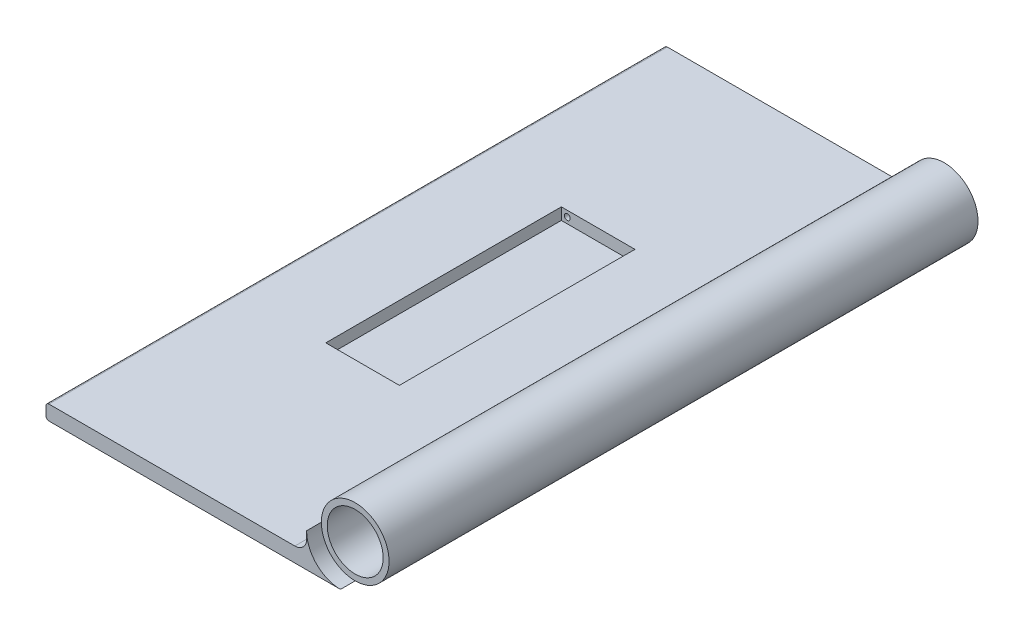
from build123d import *

# Parameters (mm, degrees)
SKETCH_1_R               = 11.5
SKETCH_1_R_2             = 9.5
EXTRUDE_1_DEPTH          = 200
EXTRUDE_2_DEPTH          = 5
EXTRUDE_2_DEPTH_BACK     = 205
SKETCH_3_W               = 25
SKETCH_3_H               = 80
CUT_EXTRUDE_1_DEPTH      = 4
SKETCH_4_R               = 1
CUT_EXTRUDE_2_DEPTH      = 81
CUT_EXTRUDE_2_DEPTH_BACK = 4


with BuildPart() as part:
    # 草图1 → 凸台-拉伸1 (new body)
    with BuildSketch(Plane.XY):
        with BuildLine():
            ThreePointArc((0, -11.5), (-8.131727984, -8.131727984), (-11.5, 0))
            Line((-11.5, 0), (-11.5, -2.5))
            ThreePointArc((-11.5, -2.5), (-12.671572875, -5.328427125), (-15.5, -6.5))
            Line((-15.5, -6.5), (-99, -6.5))
            ThreePointArc((-99, -6.5), (-99.707106781, -6.792893219), (-100, -7.5))
            Line((-100, -7.5), (-100, -10.5))
            ThreePointArc((-100, -10.5), (-99.707106781, -11.207106781), (-99, -11.5))
            Line((-99, -11.5), (0, -11.5))
        make_face()
        Circle(SKETCH_1_R)
        Circle(SKETCH_1_R_2, mode=Mode.SUBTRACT)
    extrude(amount=EXTRUDE_1_DEPTH)

    # 草图2 → 凸台-拉伸2 (add, two sides)
    with BuildSketch(Plane(origin=(0, 0, 0), x_dir=(-1, 0, 0), z_dir=(0, 0, -1))) as extrude_2_sk:
        with BuildLine():
            Line((11.5, -2.5), (11.5, 0))
            ThreePointArc((11.5, 0), (8.131727984, -8.131727984), (0, -11.5))
            Line((0, -11.5), (99, -11.5))
            ThreePointArc((99, -11.5), (99.707106781, -11.207106781), (100, -10.5))
            Line((100, -10.5), (100, -7.5))
            ThreePointArc((100, -7.5), (99.707106781, -6.792893219), (99, -6.5))
            Line((99, -6.5), (15.5, -6.5))
            ThreePointArc((15.5, -6.5), (12.671572875, -5.328427125), (11.5, -2.5))
        make_face()
    extrude(amount=EXTRUDE_2_DEPTH)
    extrude(extrude_2_sk.sketch, amount=-EXTRUDE_2_DEPTH_BACK)

    # 草图3 → 切除-拉伸1 (cut)
    with BuildSketch(Plane(origin=(0, -6.5, 0), x_dir=(1, 0, 0), z_dir=(0, 1, 0))):
        with Locations((-57.5, -100)):
            Rectangle(SKETCH_3_W, SKETCH_3_H)
    extrude(amount=-CUT_EXTRUDE_1_DEPTH, mode=Mode.SUBTRACT)

    # 草图4 → 切除-拉伸2 (cut, two sides)
    with BuildSketch(Plane.XY.offset(60)) as cut_extrude_2_sk:
        with Locations((-68, -8.5)):
            Circle(SKETCH_4_R)
    extrude(amount=CUT_EXTRUDE_2_DEPTH, mode=Mode.SUBTRACT)
    extrude(cut_extrude_2_sk.sketch, amount=-CUT_EXTRUDE_2_DEPTH_BACK, mode=Mode.SUBTRACT)


solid = part.part
